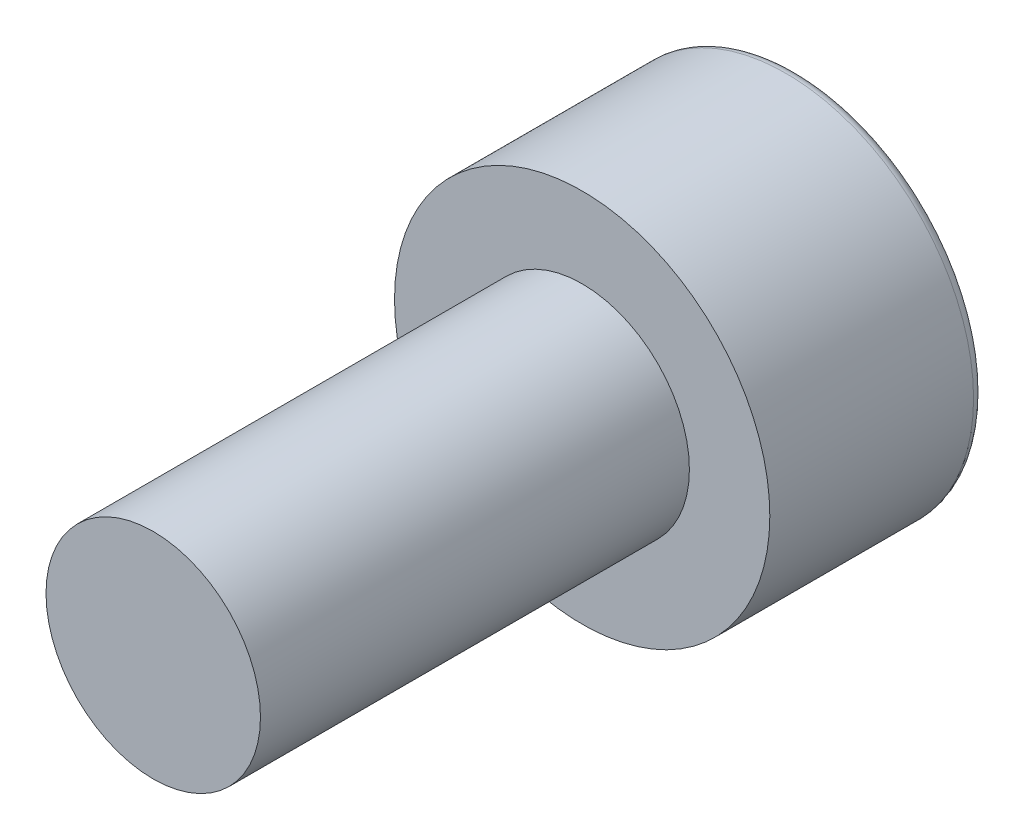
from build123d import *

# Parameters (mm, degrees)
SKETCH_1_R          = 2
EXTRUDE_1_DEPTH     = 8
SKETCH_2_R          = 3.5
EXTRUDE_2_DEPTH     = 4
CUT_EXTRUDE_1_DEPTH = 2
FILLET_1_R          = 0.2


with BuildPart() as part:
    # 草图1 → 凸台-拉伸1 (new body)
    with BuildSketch(Plane.XY):
        Circle(SKETCH_1_R)
    extrude(amount=EXTRUDE_1_DEPTH)

    # 草图2 → 凸台-拉伸2 (add)
    with BuildSketch(Plane.XY):
        Circle(SKETCH_2_R)
    extrude(amount=-EXTRUDE_2_DEPTH)

    # 草图3 → 切除-拉伸1 (cut)
    with BuildSketch(Plane(origin=(0, 0, -4), x_dir=(-1, 0, 0), z_dir=(0, 0, -1))):
        Polygon((0, 1.72), (-1.5, 0.863623327), (-1.5, -0.863623327), (0, -1.72), (1.5, -0.863623327), (1.5, 0.863623327), align=None)
    extrude(amount=-CUT_EXTRUDE_1_DEPTH, mode=Mode.SUBTRACT)

    # 圆角1
    fillet_1_edges = [part.edges().sort_by_distance(p)[0] for p in [
        (-3.5, 0, -4),
    ]]
    fillet(fillet_1_edges, radius=FILLET_1_R)


solid = part.part
